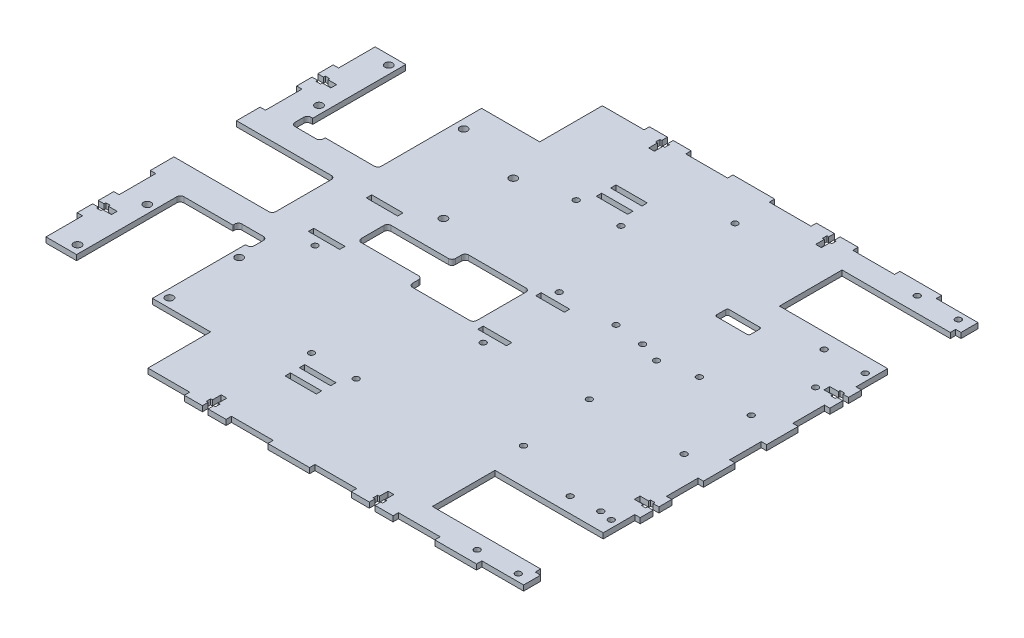
from build123d import *

# Parameters (mm, degrees)
SKETCH1_R               = 2.15
SKETCH1_R_2             = 1.65
BOSS_EXTRUDE1_DEPTH     = 3
SKETCH2_R               = 1.65
CUT_EXTRUDE1_DEPTH      = 1
CUT_EXTRUDE1_DEPTH_BACK = 4
SKETCH3_R               = 1.65
CUT_EXTRUDE2_DEPTH      = 1
CUT_EXTRUDE2_DEPTH_BACK = 4
SKETCH4_R               = 1.65
CUT_EXTRUDE3_DEPTH      = 1
CUT_EXTRUDE3_DEPTH_BACK = 4
SKETCH6_W               = 36
SKETCH6_H               = 16.7
CUT_EXTRUDE5_DEPTH      = 1
CUT_EXTRUDE5_DEPTH_BACK = 4
FILLET1_R               = 2
SKETCH5_W               = 3
SKETCH5_H               = 20.444444444
SKETCH5_H_2             = 17.666666667
SKETCH5_H_3             = 17.666666666
SKETCH5_W_2             = 23.333333333
SKETCH5_H_4             = 3
SKETCH5_W_3             = 23.333333334
CUT_EXTRUDE4_DEPTH      = 1
CUT_EXTRUDE4_DEPTH_BACK = 4
SKETCH7_R               = 1.65
SKETCH7_W               = 17.5
SKETCH7_H               = 3
SKETCH7_W_2             = 17.4795
SKETCH7_W_3             = 16
CUT_EXTRUDE6_DEPTH      = 1
CUT_EXTRUDE6_DEPTH_BACK = 4
CUT_EXTRUDE7_DEPTH      = 1
CUT_EXTRUDE7_DEPTH_BACK = 4
SKETCH9_W               = 55
SKETCH9_H               = 35
CUT_EXTRUDE8_DEPTH      = 1
CUT_EXTRUDE8_DEPTH_BACK = 4
FILLET2_R               = 2


with BuildPart() as part:
    # Sketch1 → Boss-Extrude1 (new body)
    with BuildSketch(Plane(origin=(0, 0, 0), x_dir=(1, 0, 0), z_dir=(0, 1, 0))):
        Polygon((-132.3981, 92), (-152.5, 92), (-152.5, -92), (-132.3981, -92), (-132.3981, -34), (-103.0019, -34), (-103.0019, -31), (-87.0019, -31), (-87.0019, -40), (-90.0019, -40), (-90.0019, -92), (-57.5, -92), (-57.5, -130), (152.5, -130), (152.5, -114.5), (89, -114.5), (89, -79.5), (152.5, -79.5), (152.5, 79.5), (89, 79.5), (89, 114.5), (152.5, 114.5), (152.5, 130), (-57.5, 130), (-57.5, 92), (-90.0019, 92), (-90.0019, 34), (-119.3981, 34), (-119.3981, 31), (-135.3981, 31), (-135.3981, 40), (-132.3981, 40), align=None)
        with Locations((-136.89065, -87)):
            Circle(SKETCH1_R, mode=Mode.SUBTRACT)
        with Locations((-85.50935, -87)):
            Circle(SKETCH1_R, mode=Mode.SUBTRACT)
        with Locations((-136.89065, -48)):
            Circle(SKETCH1_R, mode=Mode.SUBTRACT)
        with Locations((-85.50935, -48)):
            Circle(SKETCH1_R, mode=Mode.SUBTRACT)
        with Locations((122.5, -123)):
            Circle(SKETCH1_R_2, mode=Mode.SUBTRACT)
        with Locations((145.5, -123)):
            Circle(SKETCH1_R_2, mode=Mode.SUBTRACT)
        with Locations((122.5, -71)):
            Circle(SKETCH1_R_2, mode=Mode.SUBTRACT)
        with Locations((145.5, -71)):
            Circle(SKETCH1_R_2, mode=Mode.SUBTRACT)
        with Locations((-136.8906, 48)):
            Circle(SKETCH1_R, mode=Mode.SUBTRACT)
        with Locations((-47.3096, 28)):
            Circle(SKETCH1_R, mode=Mode.SUBTRACT)
        with Locations((-136.8906, 87)):
            Circle(SKETCH1_R, mode=Mode.SUBTRACT)
        with Locations((-85.0019, 77)):
            Circle(SKETCH1_R, mode=Mode.SUBTRACT)
        with Locations((-47.3096, 67)):
            Circle(SKETCH1_R, mode=Mode.SUBTRACT)
        with Locations((122.5, 71)):
            Circle(SKETCH1_R_2, mode=Mode.SUBTRACT)
        with Locations((145.5, 71)):
            Circle(SKETCH1_R_2, mode=Mode.SUBTRACT)
        with Locations((122.5, 123)):
            Circle(SKETCH1_R_2, mode=Mode.SUBTRACT)
        with Locations((145.5, 123)):
            Circle(SKETCH1_R_2, mode=Mode.SUBTRACT)
    extrude(amount=BOSS_EXTRUDE1_DEPTH)

    # Sketch2 → Cut-Extrude1 (cut, two sides)
    with BuildSketch(Plane(origin=(0, 3, 0), x_dir=(1, 0, 0), z_dir=(0, 1, 0))) as cut_extrude1_sk:
        with Locations((81, 18.75)):
            Circle(SKETCH2_R)
        with Locations((134, 18.75)):
            Circle(SKETCH2_R)
        with Locations((134, -18.75)):
            Circle(SKETCH2_R)
        with Locations((81, -18.75)):
            Circle(SKETCH2_R)
    extrude(amount=CUT_EXTRUDE1_DEPTH, mode=Mode.SUBTRACT)
    extrude(cut_extrude1_sk.sketch, amount=-CUT_EXTRUDE1_DEPTH_BACK, mode=Mode.SUBTRACT)

    # Sketch3 → Cut-Extrude2 (cut, two sides)
    with BuildSketch(Plane(origin=(0, 3, 0), x_dir=(1, 0, 0), z_dir=(0, 1, 0))) as cut_extrude2_sk:
        with Locations((69.205, 22.774)):
            Circle(SKETCH3_R)
        with Locations((100.955, 22.774)):
            Circle(SKETCH3_R)
        with Locations((85.08, -59.649)):
            Circle(SKETCH3_R)
        with Locations((138.42, 50.206)):
            Circle(SKETCH3_R)
        with Locations((138.42, -69.809)):
            Circle(SKETCH3_R)
        with BuildLine():
            Line((76.64, 56.786), (93.64, 56.786))
            ThreePointArc((93.64, 56.786), (94.347106781, 57.078893219), (94.64, 57.786))
            Line((94.64, 57.786), (94.64, 62.786))
            ThreePointArc((94.64, 62.786), (94.347106781, 63.493106781), (93.64, 63.786))
            Line((93.64, 63.786), (76.64, 63.786))
            ThreePointArc((76.64, 63.786), (75.932893219, 63.493106781), (75.64, 62.786))
            Line((75.64, 62.786), (75.64, 57.786))
            ThreePointArc((75.64, 57.786), (75.932893219, 57.078893219), (76.64, 56.786))
        make_face()
    extrude(amount=CUT_EXTRUDE2_DEPTH, mode=Mode.SUBTRACT)
    extrude(cut_extrude2_sk.sketch, amount=-CUT_EXTRUDE2_DEPTH_BACK, mode=Mode.SUBTRACT)

    # Sketch4 → Cut-Extrude3 (cut, two sides)
    with BuildSketch(Plane(origin=(0, 3, 0), x_dir=(1, 0, 0), z_dir=(0, 1, 0))) as cut_extrude3_sk:
        with Locations((20.678, 24.699)):
            Circle(SKETCH4_R)
        with Locations((52.428, 24.699)):
            Circle(SKETCH4_R)
        with Locations((36.553, 107.122)):
            Circle(SKETCH4_R)
    extrude(amount=CUT_EXTRUDE3_DEPTH, mode=Mode.SUBTRACT)
    extrude(cut_extrude3_sk.sketch, amount=-CUT_EXTRUDE3_DEPTH_BACK, mode=Mode.SUBTRACT)

    # Sketch6 → Cut-Extrude5 (cut, two sides)
    with BuildSketch(Plane(origin=(0, 3, 0), x_dir=(1, 0, 0), z_dir=(0, 1, 0))) as cut_extrude5_sk:
        with Locations((-42.6174, 1.7)):
            Rectangle(SKETCH6_W, SKETCH6_H)
        Polygon((-24.6174, 10.05), (-24.6174, -6.65), (-24.6174, -14), (11.3826, -14), (11.3826, 17.4), (-24.6174, 17.4), align=None)
    extrude(amount=CUT_EXTRUDE5_DEPTH, mode=Mode.SUBTRACT)
    extrude(cut_extrude5_sk.sketch, amount=-CUT_EXTRUDE5_DEPTH_BACK, mode=Mode.SUBTRACT)

    # Fillet1
    fillet1_edges = [part.edges().sort_by_distance(p)[0] for p in [
        (-24.6174, 1.5, 6.65),
        (-60.6174, 1.5, 6.65),
        (-60.6174, 1.5, -10.05),
        (-24.6174, 1.5, -10.05),
        (-24.6174, 1.5, -17.4),
        (11.3826, 1.5, -17.4),
        (11.3826, 1.5, 14),
        (-24.6174, 1.5, 14),
    ]]
    fillet(fillet1_edges, radius=FILLET1_R)

    # Sketch5 → Cut-Extrude4 (cut, two sides)
    with BuildSketch(Plane(origin=(0, 3, 0), x_dir=(1, 0, 0), z_dir=(0, 1, 0))) as cut_extrude4_sk:
        with Locations((-151, 81.777777778)):
            Rectangle(SKETCH5_W, SKETCH5_H)
        with Locations((-151, 40.888888889)):
            Rectangle(SKETCH5_W, SKETCH5_H)
        with Locations((-151, 0)):
            Rectangle(SKETCH5_W, SKETCH5_H)
        with Locations((-151, -40.888888889)):
            Rectangle(SKETCH5_W, SKETCH5_H)
        with Locations((-151, -81.777777778)):
            Rectangle(SKETCH5_W, SKETCH5_H)
        with Locations((151, 70.666666667)):
            Rectangle(SKETCH5_W, SKETCH5_H_2)
        with Locations((151, 35.333333334)):
            Rectangle(SKETCH5_W, SKETCH5_H_2)
        with Locations((151, 0)):
            Rectangle(SKETCH5_W, SKETCH5_H_3)
        with Locations((151, -35.333333334)):
            Rectangle(SKETCH5_W, SKETCH5_H_2)
        with Locations((151, -70.666666667)):
            Rectangle(SKETCH5_W, SKETCH5_H_2)
        with Locations((-45.833333334, 128.5)):
            Rectangle(SKETCH5_W_2, SKETCH5_H_4)
        with Locations((0.833333333, 128.5)):
            Rectangle(SKETCH5_W_2, SKETCH5_H_4)
        with Locations((47.5, 128.5)):
            Rectangle(SKETCH5_W_3, SKETCH5_H_4)
        with Locations((94.166666667, 128.5)):
            Rectangle(SKETCH5_W_2, SKETCH5_H_4)
        with Locations((140.833333334, 128.5)):
            Rectangle(SKETCH5_W_2, SKETCH5_H_4)
        with Locations((151, 116)):
            Rectangle(SKETCH5_W, SKETCH5_H_4)
        with Locations((151, -116)):
            Rectangle(SKETCH5_W, SKETCH5_H_4)
        with Locations((140.833333334, -128.5)):
            Rectangle(SKETCH5_W_2, SKETCH5_H_4)
        with Locations((94.166666667, -128.5)):
            Rectangle(SKETCH5_W_2, SKETCH5_H_4)
        with Locations((47.5, -128.5)):
            Rectangle(SKETCH5_W_3, SKETCH5_H_4)
        with Locations((0.833333333, -128.5)):
            Rectangle(SKETCH5_W_2, SKETCH5_H_4)
        with Locations((-45.833333334, -128.5)):
            Rectangle(SKETCH5_W_2, SKETCH5_H_4)
    extrude(amount=CUT_EXTRUDE4_DEPTH, mode=Mode.SUBTRACT)
    extrude(cut_extrude4_sk.sketch, amount=-CUT_EXTRUDE4_DEPTH_BACK, mode=Mode.SUBTRACT)

    # Sketch7 → Cut-Extrude6 (cut, two sides)
    with BuildSketch(Plane(origin=(0, 3, 0), x_dir=(1, 0, 0), z_dir=(0, 1, 0))) as cut_extrude6_sk:
        with Locations((-19.1174, 74)):
            Circle(SKETCH7_R)
        with Locations((5.8826, 74)):
            Circle(SKETCH7_R)
        with Locations((-19.1174, -74)):
            Circle(SKETCH7_R)
        with Locations((5.8826, -74)):
            Circle(SKETCH7_R)
        with Locations((-70.0912, -21)):
            Circle(SKETCH7_R)
        with Locations((23.8826, -21)):
            Circle(SKETCH7_R)
        with Locations((-70.0912, -14.5)):
            Rectangle(SKETCH7_W, SKETCH7_H)
        with Locations((-6.6174, -91)):
            Rectangle(SKETCH7_W_2, SKETCH7_H)
        with Locations((-6.6174, -83)):
            Rectangle(SKETCH7_W_2, SKETCH7_H)
        with Locations((-6.6174, 91)):
            Rectangle(SKETCH7_W_2, SKETCH7_H)
        with Locations((-6.6174, 83)):
            Rectangle(SKETCH7_W_2, SKETCH7_H)
        with Locations((-70.0912, 17.9)):
            Rectangle(SKETCH7_W, SKETCH7_H)
        with Locations((23.8826, -14.5)):
            Rectangle(SKETCH7_W_3, SKETCH7_H)
        with Locations((23.8826, 17.9)):
            Rectangle(SKETCH7_W_3, SKETCH7_H)
    extrude(amount=CUT_EXTRUDE6_DEPTH, mode=Mode.SUBTRACT)
    extrude(cut_extrude6_sk.sketch, amount=-CUT_EXTRUDE6_DEPTH_BACK, mode=Mode.SUBTRACT)

    # Sketch8 → Cut-Extrude7 (cut, two sides)
    with BuildSketch(Plane(origin=(0, 3, 0), x_dir=(1, 0, 0), z_dir=(0, 1, 0))) as cut_extrude7_sk:
        Polygon((-24.1, 124.325), (-24.1, 119.5), (-20.9, 119.5), (-20.9, 124.325), (-19.9, 124.325), (-19.9, 126.825), (-20.9, 126.825), (-20.9, 130), (-24.1, 130), (-24.1, 126.825), (-25.1, 126.825), (-25.1, 124.325), align=None)
        Polygon((69.233333333, 124.325), (69.233333333, 119.5), (72.433333333, 119.5), (72.433333333, 124.325), (73.433333333, 124.325), (73.433333333, 126.825), (72.433333333, 126.825), (72.433333333, 130), (69.233333333, 130), (69.233333333, 126.825), (68.233333333, 126.825), (68.233333333, 124.325), align=None)
        Polygon((72.433333333, -124.325), (72.433333333, -119.5), (69.233333333, -119.5), (69.233333333, -124.325), (68.233333333, -124.325), (68.233333333, -126.825), (69.233333333, -126.825), (69.233333333, -130), (72.433333333, -130), (72.433333333, -126.825), (73.433333333, -126.825), (73.433333333, -124.325), align=None)
        Polygon((-20.9, -119.5), (-24.1, -119.5), (-24.1, -124.325), (-25.1, -124.325), (-25.1, -126.825), (-24.1, -126.825), (-24.1, -130), (-20.9, -130), (-20.9, -126.825), (-19.9, -126.825), (-19.9, -124.325), (-20.9, -124.325), align=None)
        Polygon((146.825, 54.6), (142, 54.6), (142, 51.4), (146.825, 51.4), (146.825, 50.4), (149.325, 50.4), (149.325, 51.4), (152.5, 51.4), (152.5, 54.6), (149.325, 54.6), (149.325, 55.6), (146.825, 55.6), align=None)
        Polygon((146.825, -51.4), (142, -51.4), (142, -54.6), (146.825, -54.6), (146.825, -55.6), (149.325, -55.6), (149.325, -54.6), (152.5, -54.6), (152.5, -51.4), (149.325, -51.4), (149.325, -50.4), (146.825, -50.4), align=None)
        Polygon((-146.825, 59.733333333), (-142, 59.733333333), (-142, 62.933333333), (-146.825, 62.933333333), (-146.825, 63.933333333), (-149.325, 63.933333333), (-149.325, 62.933333333), (-152.5, 62.933333333), (-152.5, 59.733333333), (-149.325, 59.733333333), (-149.325, 58.733333333), (-146.825, 58.733333333), align=None)
        Polygon((-146.825, -62.933333333), (-142, -62.933333333), (-142, -59.733333333), (-146.825, -59.733333333), (-146.825, -58.733333333), (-149.325, -58.733333333), (-149.325, -59.733333333), (-152.5, -59.733333333), (-152.5, -62.933333333), (-149.325, -62.933333333), (-149.325, -63.933333333), (-146.825, -63.933333333), align=None)
    extrude(amount=CUT_EXTRUDE7_DEPTH, mode=Mode.SUBTRACT)
    extrude(cut_extrude7_sk.sketch, amount=-CUT_EXTRUDE7_DEPTH_BACK, mode=Mode.SUBTRACT)

    # Sketch9 → Cut-Extrude8 (cut, two sides)
    with BuildSketch(Plane(origin=(0, 3, 0), x_dir=(1, 0, 0), z_dir=(0, 1, 0))) as cut_extrude8_sk:
        with Locations((-125, 0)):
            Rectangle(SKETCH9_W, SKETCH9_H)
    extrude(amount=CUT_EXTRUDE8_DEPTH, mode=Mode.SUBTRACT)
    extrude(cut_extrude8_sk.sketch, amount=-CUT_EXTRUDE8_DEPTH_BACK, mode=Mode.SUBTRACT)

    # Fillet2
    fillet2_edges = [part.edges().sort_by_distance(p)[0] for p in [
        (-97.5, 1.5, -17.5),
        (-97.5, 1.5, 17.5),
        (-90.0019, 1.5, -34),
        (-87.0019, 1.5, 40),
        (-87.0019, 1.5, 31),
        (-103.0019, 1.5, 31),
        (-132.3981, 1.5, 34),
        (-135.3981, 1.5, -40),
        (-135.3981, 1.5, -31),
        (-119.3981, 1.5, -31),
    ]]
    fillet(fillet2_edges, radius=FILLET2_R)


solid = part.part
